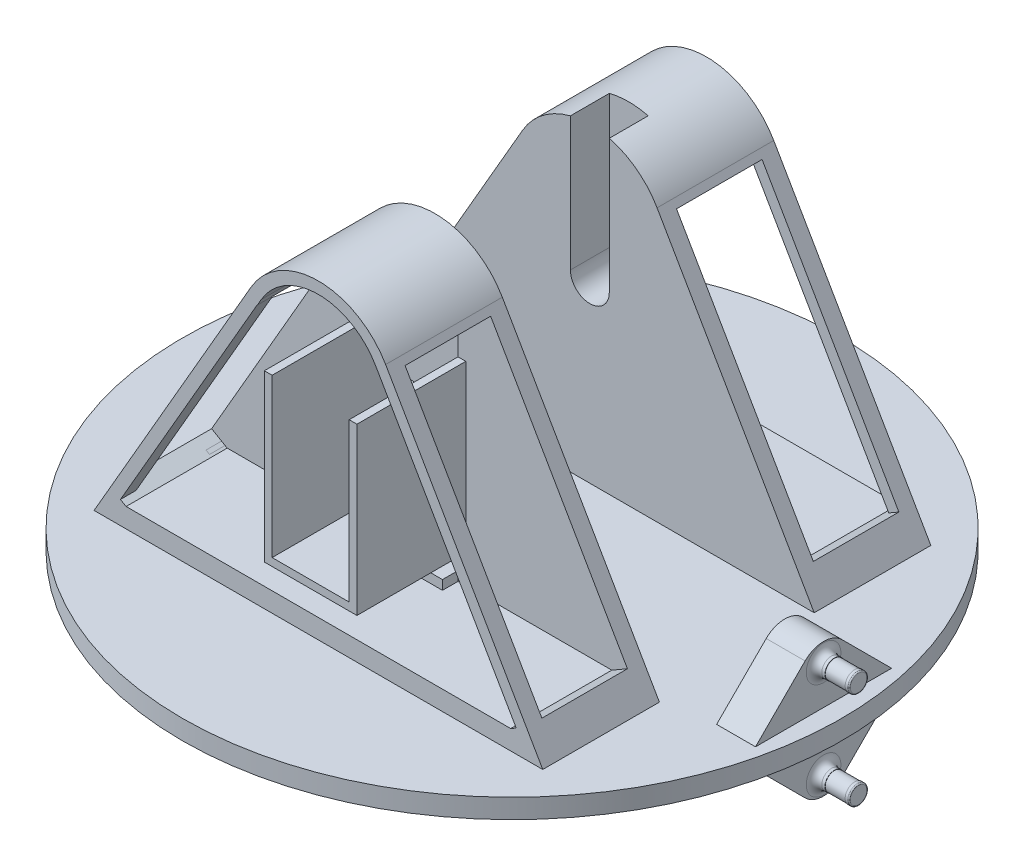
from build123d import *

# Parameters (mm, degrees)
SKETCH2_W            = 200
SKETCH2_H            = 200
BOSS_EXTRUDE2_DEPTH  = 60
BOSS_EXTRUDE3_START  = -38
BOSS_EXTRUDE3_DEPTH  = 41
SKETCH5_W            = 180
SKETCH5_H            = 180
CUT_EXTRUDE2_DEPTH   = 50
BOSS_EXTRUDE4_START  = -51.2
BOSS_EXTRUDE4_DEPTH  = 30
CUT_EXTRUDE3_DEPTH   = 35
SKETCH9_R            = 5
CUT_EXTRUDE4_DEPTH   = 10
CUT_EXTRUDE6_DEPTH   = 26
SKETCH11_W           = 120
SKETCH11_H           = 10
CUT_EXTRUDE7_DEPTH   = 26
SKETCH12_W           = 180
SKETCH12_H           = 50
CUT_EXTRUDE8_DEPTH   = 200
SKETCH13_W           = 180
SKETCH13_H           = 50
CUT_EXTRUDE9_DEPTH   = 200
SKETCH15_W           = 19.8
SKETCH15_H           = 40.6
SKETCH15_R           = 4.016151872
CUT_EXTRUDE11_DEPTH  = 10
BOSS_EXTRUDE5_DEPTH  = 26
SKETCH20_W           = 19.8
SKETCH20_H           = 7
CUT_EXTRUDE14_DEPTH  = 8.2
SKETCH22_W           = 22
SKETCH22_H           = 68.38628635
SKETCH22_W_2         = 33
SKETCH22_H_2         = 70.357034464
CUT_EXTRUDE16_DEPTH  = 6
CUT_EXTRUDE17_DEPTH  = 150
SKETCH24_W           = 190
SKETCH24_H           = 55
CUT_EXTRUDE18_DEPTH  = 200
SKETCH41_W           = 200
SKETCH41_H           = 200
SKETCH41_W_2         = 115.381197846
SKETCH41_H_2         = 110.8
CUT_EXTRUDE25_DEPTH  = 100
CUT_EXTRUDE26_DEPTH  = 26
SKETCH43_R           = 85
BOSS_EXTRUDE9_DEPTH  = 5
CUT_EXTRUDE27_DEPTH  = 11
BOSS_EXTRUDE10_DEPTH = 4
BOSS_EXTRUDE11_DEPTH = 24
BOSS_EXTRUDE12_DEPTH = 26
BOSS_EXTRUDE14_DEPTH = 4
CUT_EXTRUDE29_DEPTH  = 18
CUT_EXTRUDE30_DEPTH  = 2
CUT_EXTRUDE31_DEPTH  = 2
SKETCH55_W           = 19.8
SKETCH55_H           = 2.410200662
BOSS_EXTRUDE16_DEPTH = 4
SKETCH56_W           = 22
SKETCH56_H           = 70.356823689
CUT_EXTRUDE32_DEPTH  = 4
BOSS_EXTRUDE17_DEPTH = 26
BOSS_EXTRUDE18_DEPTH = 26
BOSS_EXTRUDE19_START = 170
BOSS_EXTRUDE19_DEPTH = 10
SKETCH60_R           = 2.45
BOSS_EXTRUDE20_DEPTH = 9
FILLET1_R            = 0.3
CUT_EXTRUDE33_START  = -1
SKETCH61_R           = 2.45
SKETCH61_R_2         = 2.375
CUT_EXTRUDE33_DEPTH  = 5.2
FILLET2_R            = 2
BOSS_EXTRUDE21_START = 140
BOSS_EXTRUDE21_DEPTH = 10
SKETCH63_R           = 2.45
BOSS_EXTRUDE22_DEPTH = 9
FILLET3_R            = 0.3
FILLET4_R            = 2
CUT_EXTRUDE34_START  = -1
SKETCH64_R           = 2.45
SKETCH64_R_2         = 2.375
CUT_EXTRUDE34_DEPTH  = 5.2
SKETCH67_R           = 95.168377016
SKETCH67_R_2         = 84.75
CUT_EXTRUDE36_DEPTH  = 5


with BuildPart() as part:
    # Sketch2 → Boss-Extrude2 (new body)
    with BuildSketch(Plane(origin=(0, 0, 0), x_dir=(1, 0, 0), z_dir=(0, 1, 0))):
        with Locations((100, 100)):
            Rectangle(SKETCH2_W, SKETCH2_H)
    extrude(amount=BOSS_EXTRUDE2_DEPTH)

    # Sketch3 → Boss-Extrude3 (add)
    with BuildSketch(Plane.XY.offset(BOSS_EXTRUDE3_START)):
        with BuildLine():
            Line((40, 60), (80.980762114, 130.980762114))
            ThreePointArc((80.980762114, 130.980762114), (100, 141.961524227), (119.019237886, 130.980762114))
            Line((119.019237886, 130.980762114), (160, 60))
            Line((160, 60), (40, 60))
        make_face()
    extrude(amount=-BOSS_EXTRUDE3_DEPTH)

    # Sketch5 → Cut-Extrude2 (cut)
    with BuildSketch(Plane.XZ):
        with Locations((100, -100)):
            Rectangle(SKETCH5_W, SKETCH5_H)
    extrude(amount=-CUT_EXTRUDE2_DEPTH, mode=Mode.SUBTRACT)

    # Sketch7 → Boss-Extrude4 (add)
    with BuildSketch(Plane(origin=(0, 0, -200), x_dir=(-1, 0, 0), z_dir=(0, 0, -1)).offset(BOSS_EXTRUDE4_START)):
        with BuildLine():
            Line((-160, 60), (-40, 60))
            Line((-40, 60), (-80.980762114, 130.980762114))
            ThreePointArc((-80.980762114, 130.980762114), (-100, 141.961524227), (-119.019237886, 130.980762114))
            Line((-119.019237886, 130.980762114), (-160, 60))
        make_face()
    extrude(amount=-BOSS_EXTRUDE4_DEPTH)

    # Sketch8 → Cut-Extrude3 (cut)
    with BuildSketch(Plane.XY.offset(-38)):
        with BuildLine():
            Line((48.660254038, 65), (151.339745962, 65))
            Line((151.339745962, 65), (114.689110868, 128.480762114))
            ThreePointArc((114.689110868, 128.480762114), (100, 136.961524227), (85.310889132, 128.480762114))
            Line((85.310889132, 128.480762114), (48.660254038, 65))
        make_face()
    extrude(amount=-CUT_EXTRUDE3_DEPTH, mode=Mode.SUBTRACT)

    # Sketch9 → Cut-Extrude4 (cut)
    with BuildSketch(Plane.XY.offset(-118.8)):
        with BuildLine():
            Line((95, 141.384773704), (95, 105))
            ThreePointArc((95, 105), (100, 110), (105, 105))
            Line((105, 105), (105, 141.384773704))
            ThreePointArc((105, 141.384773704), (100, 141.961524227), (95, 141.384773704))
        make_face()
        with Locations((100, 105)):
            Circle(SKETCH9_R)
    extrude(amount=-CUT_EXTRUDE4_DEPTH, mode=Mode.SUBTRACT)

    # Sketch10 → Cut-Extrude6 (cut)
    with BuildSketch(Plane(origin=(0, 0, -148.8), x_dir=(-1, 0, 0), z_dir=(0, 0, -1))):
        with BuildLine():
            Line((-110, 105), (-110, 133.700120587))
            ThreePointArc((-110, 133.700120587), (-112.617387787, 131.335555987), (-114.689110868, 128.480762114))
            Line((-114.689110868, 128.480762114), (-151.339745962, 65))
            Line((-151.339745962, 65), (-48.660254038, 65))
            Line((-48.660254038, 65), (-85.310889132, 128.480762114))
            ThreePointArc((-85.310889132, 128.480762114), (-87.382612213, 131.335555987), (-90, 133.700120587))
            Line((-90, 133.700120587), (-90, 105))
            ThreePointArc((-90, 105), (-100, 95), (-110, 105))
        make_face()
    extrude(amount=-CUT_EXTRUDE6_DEPTH, mode=Mode.SUBTRACT)

    # Sketch11 → Cut-Extrude7 (cut)
    with BuildSketch(Plane(origin=(0, 60, 0), x_dir=(1, 0, 0), z_dir=(0, 1, 0))):
        with Locations((100, 113.8)):
            Rectangle(SKETCH11_W, SKETCH11_H)
    extrude(amount=-CUT_EXTRUDE7_DEPTH, mode=Mode.SUBTRACT)

    # Sketch12 → Cut-Extrude8 (cut)
    with BuildSketch(Plane(origin=(200, 0, 0), x_dir=(0, 0, -1), z_dir=(1, 0, 0))):
        with Locations((100, 25)):
            Rectangle(SKETCH12_W, SKETCH12_H)
    extrude(amount=-CUT_EXTRUDE8_DEPTH, mode=Mode.SUBTRACT)

    # Sketch13 → Cut-Extrude9 (cut)
    with BuildSketch(Plane.XY):
        with Locations((100, 25)):
            Rectangle(SKETCH13_W, SKETCH13_H)
    extrude(amount=-CUT_EXTRUDE9_DEPTH, mode=Mode.SUBTRACT)

    # Sketch15 → Cut-Extrude11 (cut)
    with BuildSketch(Plane.XY.offset(-73)):
        with Locations((100, 94.7)):
            Rectangle(SKETCH15_W, SKETCH15_H)
        with Locations((100, 105)):
            Circle(SKETCH15_R, mode=Mode.SUBTRACT)
        with Locations((100, 105)):
            Circle(SKETCH15_R)
    extrude(amount=-CUT_EXTRUDE11_DEPTH, mode=Mode.SUBTRACT)

    # Sketch16 → Boss-Extrude5 (add)
    with BuildSketch(Plane.XY.offset(-73)):
        Polygon((88.1, 115), (88.1, 72.4), (111.9, 72.4), (111.9, 115), (109.9, 115), (109.9, 74.4), (90.1, 74.4), (90.1, 115), align=None)
    extrude(amount=BOSS_EXTRUDE5_DEPTH)

    # Sketch20 → Cut-Extrude14 (cut)
    with BuildSketch(Plane(origin=(0, 0, -79), x_dir=(-1, 0, 0), z_dir=(0, 0, -1))):
        with Locations((-100, 118.5)):
            Rectangle(SKETCH20_W, SKETCH20_H)
        with Locations((-100, 70.9)):
            Rectangle(SKETCH20_W, SKETCH20_H)
    extrude(amount=-CUT_EXTRUDE14_DEPTH, mode=Mode.SUBTRACT)

    # Sketch22 → Cut-Extrude16 (cut)
    with BuildSketch(Plane(origin=(4.019237886, -2.320508076, 0), x_dir=(0, 0, 1), z_dir=(-0.8660254037844397, 0.49999999999999806, 0))):
        with Locations((-133.8, 115.729905279)):
            Rectangle(SKETCH22_W, SKETCH22_H)
        with Locations((-58.5, 116.744531222)):
            Rectangle(SKETCH22_W_2, SKETCH22_H_2)
    extrude(amount=-CUT_EXTRUDE16_DEPTH, mode=Mode.SUBTRACT)

    # Sketch23 → Cut-Extrude17 (cut)
    with BuildSketch(Plane.XY.offset(-38)):
        with BuildLine():
            Line((43.464101615, 62), (42.309401077, 60))
            Line((42.309401077, 60), (36.951802896, 60))
            Line((36.951802896, 60), (100, 183.688158135))
            Line((100, 183.688158135), (162.604774917, 60))
            Line((162.604774917, 60), (157.690598923, 60))
            Line((157.690598923, 60), (156.535898385, 62))
            Line((156.535898385, 62), (117.287187079, 129.980762114))
            ThreePointArc((117.287187079, 129.980762114), (100, 139.961524227), (82.712812921, 129.980762114))
            Line((82.712812921, 129.980762114), (43.464101615, 62))
        make_face()
    extrude(amount=-CUT_EXTRUDE17_DEPTH, mode=Mode.SUBTRACT)

    # Sketch24 → Cut-Extrude18 (cut)
    with BuildSketch(Plane(origin=(0, 0, -200), x_dir=(-1, 0, 0), z_dir=(0, 0, -1))):
        with Locations((-100, 27.5)):
            Rectangle(SKETCH24_W, SKETCH24_H)
    extrude(amount=-CUT_EXTRUDE18_DEPTH, mode=Mode.SUBTRACT)

    # Sketch41 → Cut-Extrude25 (cut)
    with BuildSketch(Plane(origin=(0, 60, 0), x_dir=(1, 0, 0), z_dir=(0, 1, 0))):
        with Locations((100, 100)):
            Rectangle(SKETCH41_W, SKETCH41_H)
        with Locations((100, 93.4)):
            Rectangle(SKETCH41_W_2, SKETCH41_H_2, mode=Mode.SUBTRACT)
    extrude(amount=-CUT_EXTRUDE25_DEPTH, mode=Mode.SUBTRACT)


with BuildPart() as cut_extrude25_piece_1:
    # of the separate pieces the step leaves, piece 1, a body of its own (cut_extrude25_pieces)
    add(part.part.solids().sort_by_distance((42.309401077, 55, -108.8))[0])



with BuildPart() as cut_extrude25_piece_2:
    # of the separate pieces the step leaves, piece 2, a body of its own (cut_extrude25_pieces)
    add(part.part.solids().sort_by_distance((42.309401077, 55, -118.8))[0])

    # Sketch38 → Cut-Extrude26 (cut)
    with BuildSketch(Plane(origin=(0, 0, -148.8), x_dir=(-1, 0, 0), z_dir=(0, 0, -1))):
        with BuildLine():
            Line((-110, 133.700120587), (-107, 135.763853262))
            Line((-107, 135.763853262), (-107, 105))
            ThreePointArc((-107, 105), (-100, 98), (-93, 105))
            Line((-93, 105), (-93, 135.763853262))
            Line((-93, 135.763853262), (-90, 133.700120587))
            Line((-90, 133.700120587), (-90, 105))
            ThreePointArc((-90, 105), (-100, 95), (-110, 105))
            Line((-110, 105), (-110, 133.700120587))
        make_face()
    extrude(amount=-CUT_EXTRUDE26_DEPTH, mode=Mode.SUBTRACT)


with BuildPart() as cut_extrude25_piece_1_1:
    add(cut_extrude25_piece_1.part)

    add(cut_extrude25_piece_2.part)  # Boss-Extrude9 merges Cut-Extrude25 piece 2
    # Sketch43 → Boss-Extrude9 (add)
    with BuildSketch(Plane.XZ.offset(-55)):
        with Locations(Location((100, -98.8, 0), (0, 0, 270))):
            Circle(SKETCH43_R)
    extrude(amount=-BOSS_EXTRUDE9_DEPTH)

    # Sketch45 → Cut-Extrude27 (cut)
    with BuildSketch(Plane.XY.offset(-38)):
        with BuildLine():
            Line((42.309401077, 60), (82.712812921, 129.980762114))
            ThreePointArc((82.712812921, 129.980762114), (100, 139.961524227), (117.287187079, 129.980762114))
            Line((117.287187079, 129.980762114), (157.690598923, 60))
            Line((157.690598923, 60), (42.309401077, 60))
        make_face()
        with BuildLine():
            Line((151.339745962, 65), (114.689110868, 128.480762114))
            ThreePointArc((114.689110868, 128.480762114), (100, 136.961524227), (85.310889132, 128.480762114))
            Line((85.310889132, 128.480762114), (48.660254038, 65))
            Line((48.660254038, 65), (151.339745962, 65))
        make_face(mode=Mode.SUBTRACT)
    extrude(amount=-CUT_EXTRUDE27_DEPTH, mode=Mode.SUBTRACT)

    # Sketch46 → Boss-Extrude10 (add)
    with BuildSketch(Plane.XY.offset(-49)):
        Polygon((81.712812921, 128.248711306), (46.534295689, 67.317732125), (49.094273419, 65.839728294), (84.272790651, 126.770707475), align=None)
    extrude(amount=-BOSS_EXTRUDE10_DEPTH)

    # Sketch47 → Boss-Extrude11 (add)
    with BuildSketch(Plane.XY.offset(-73)):
        Polygon((49.1323719, 65.817732125), (50.548725488, 65), (48.660254038, 65), align=None)
    extrude(amount=BOSS_EXTRUDE11_DEPTH)

    # Sketch48 → Boss-Extrude12 (add)
    with BuildSketch(Plane(origin=(0, 0, -122.8), x_dir=(-1, 0, 0), z_dir=(0, 0, -1))):
        Polygon((-49.117745958, 65.792399249), (-50.490221717, 65), (-48.660254038, 65), align=None)
    extrude(amount=BOSS_EXTRUDE12_DEPTH)

    # Sketch49 → Boss-Extrude14 (add)
    with BuildSketch(Plane.XY.offset(-75)):
        Polygon((49.998397304, 65.317732125), (49.094273419, 65.839728294), (84.272790651, 126.770707475), (85.176914536, 126.248711306), align=None)
    extrude(amount=BOSS_EXTRUDE14_DEPTH)

    # Sketch52 → Cut-Extrude29 (cut)
    with BuildSketch(Plane(origin=(0, 0, -148.8), x_dir=(-1, 0, 0), z_dir=(0, 0, -1))):
        with BuildLine():
            Line((-93, 135.763853262), (-93, 105))
            ThreePointArc((-93, 105), (-100, 98), (-107, 105))
            Line((-107, 105), (-107, 135.763853262))
            ThreePointArc((-107, 135.763853262), (-100, 137.248161341), (-93, 135.763853262))
        make_face()
    extrude(amount=-CUT_EXTRUDE29_DEPTH, mode=Mode.SUBTRACT)

    # Sketch53 → Cut-Extrude30 (cut)
    with BuildSketch(Plane.XY.offset(-71)):
        Polygon((85.176914536, 126.248711306), (84.272790651, 126.770707475), (49.090707581, 65.833552081), (49.994831466, 65.311555913), align=None)
    extrude(amount=-CUT_EXTRUDE30_DEPTH, mode=Mode.SUBTRACT)

    # Sketch54 → Cut-Extrude31 (cut)
    with BuildSketch(Plane.XY.offset(-73)):
        with BuildLine():
            Line((49.090707581, 65.833552081), (49.994831466, 65.311555913))
            Line((49.994831466, 65.311555913), (49.998397304, 65.317732125))
            Line((49.998397304, 65.317732125), (50.548725488, 65))
            Line((50.548725488, 65), (151.339745962, 65))
            Line((151.339745962, 65), (114.689110868, 128.480762114))
            ThreePointArc((114.689110868, 128.480762114), (100, 136.961524227), (85.310889132, 128.480762114))
            Line((85.310889132, 128.480762114), (84.310889132, 126.748711306))
            Line((84.310889132, 126.748711306), (84.272790651, 126.770707475))
            Line((84.272790651, 126.770707475), (49.094273419, 65.839728294))
            Line((49.094273419, 65.839728294), (49.090707581, 65.833552081))
        make_face()
        Polygon((90.1, 122), (109.9, 122), (109.9, 115), (111.9, 115), (111.9, 72.4), (109.9, 72.4), (109.9, 67.4), (90.1, 67.4), (90.1, 72.4), (88.1, 72.4), (88.1, 115), (90.1, 115), align=None, mode=Mode.SUBTRACT)
    extrude(amount=-CUT_EXTRUDE31_DEPTH, mode=Mode.SUBTRACT)

    # Sketch55 → Boss-Extrude16 (add)
    with BuildSketch(Plane.XY.offset(-75)):
        with Locations((100, 66.194899669)):
            Rectangle(SKETCH55_W, SKETCH55_H)
    extrude(amount=BOSS_EXTRUDE16_DEPTH)

    # Sketch56 → Cut-Extrude32 (cut)
    with BuildSketch(Plane(origin=(144.248711306, 83.282032303, 0), x_dir=(0, 0, -1), z_dir=(0.8660254037844362, 0.5000000000000044, 0))):
        with Locations((64, 16.744636609)):
            Rectangle(SKETCH56_W, SKETCH56_H)
        with Locations((133.8, 16.744636609)):
            Rectangle(SKETCH56_W, SKETCH56_H)
    extrude(amount=-CUT_EXTRUDE32_DEPTH, mode=Mode.SUBTRACT)

    # Sketch57 → Boss-Extrude17 (add)
    with BuildSketch(Plane.XY.offset(-75)):
        Polygon((150.867522712, 65.817914662), (149.450852961, 65), (151.339745962, 65), align=None)
    extrude(amount=BOSS_EXTRUDE17_DEPTH)

    # Sketch58 → Boss-Extrude18 (add)
    with BuildSketch(Plane(origin=(0, 0, -122.8), x_dir=(-1, 0, 0), z_dir=(0, 0, -1))):
        Polygon((-150.867522712, 65.817914662), (-151.339745962, 65), (-149.450852961, 65), align=None)
    extrude(amount=BOSS_EXTRUDE18_DEPTH)

    # Sketch59 → Boss-Extrude19 (add)
    with BuildSketch(Plane(origin=(0, 0, 0), x_dir=(0, 0, -1), z_dir=(1, 0, 0)).offset(BOSS_EXTRUDE19_START)):
        with BuildLine():
            Line((81.4, 60), (94.15, 72.75))
            ThreePointArc((94.15, 72.75), (98.9, 74.717514421), (103.65, 72.75))
            Line((103.65, 72.75), (116.4, 60))
            Line((116.4, 60), (81.4, 60))
        make_face()
        with BuildLine():
            Line((81.4, 55), (116.4, 55))
            Line((116.4, 55), (103.65, 42.25))
            ThreePointArc((103.65, 42.25), (98.9, 40.282485579), (94.15, 42.25))
            Line((94.15, 42.25), (81.4, 55))
        make_face()
    extrude(amount=BOSS_EXTRUDE19_DEPTH)

    # Sketch60 → Boss-Extrude20 (add)
    with BuildSketch(Plane(origin=(180, 0, 0), x_dir=(0, 0, -1), z_dir=(1, 0, 0))):
        with Locations(Location((98.9, 70, 0), (0, 0, 180))):
            Circle(SKETCH60_R)
        with Locations(Location((98.9, 45, 0), (0, 0, 180))):
            Circle(SKETCH60_R)
    extrude(amount=BOSS_EXTRUDE20_DEPTH)

    # Fillet1
    fillet1_edges = [cut_extrude25_piece_1_1.edges().sort_by_distance(p)[0] for p in [
        (189, 70, -101.35),
        (189, 45, -101.35),
    ]]
    fillet(fillet1_edges, radius=FILLET1_R)

    # Sketch61 → Cut-Extrude33 (cut)
    with BuildSketch(Plane(origin=(189, 0, 0), x_dir=(0, 0, -1), z_dir=(1, 0, 0)).offset(CUT_EXTRUDE33_START)):
        with Locations(Location((98.9, 70, 0), (0, 0, 180))):
            Circle(SKETCH61_R)
        with Locations((98.9, 70)):
            Circle(SKETCH61_R_2, mode=Mode.SUBTRACT)
        with Locations(Location((98.9, 45, 0), (0, 0, 180))):
            Circle(SKETCH61_R)
        with Locations(Location((98.9, 45, 0), (0, 0, 180))):
            Circle(SKETCH61_R_2, mode=Mode.SUBTRACT)
    extrude(amount=-CUT_EXTRUDE33_DEPTH, mode=Mode.SUBTRACT)

    # Fillet2
    fillet2_edges = [cut_extrude25_piece_1_1.edges().sort_by_distance(p)[0] for p in [
        (180, 70, -101.35),
        (180, 45, -101.35),
    ]]
    fillet(fillet2_edges, radius=FILLET2_R)

    # Sketch62 → Boss-Extrude21 (add)
    with BuildSketch(Plane.ZY.offset(-170).offset(BOSS_EXTRUDE21_START)):
        with BuildLine():
            Line((-81.4, 55), (-94.15, 42.25))
            ThreePointArc((-94.15, 42.25), (-98.9, 40.282485579), (-103.65, 42.25))
            Line((-103.65, 42.25), (-116.4, 55))
            Line((-116.4, 55), (-81.4, 55))
        make_face()
    extrude(amount=BOSS_EXTRUDE21_DEPTH)

    # Sketch63 → Boss-Extrude22 (add)
    with BuildSketch(Plane.ZY.offset(-20)):
        with Locations((-98.9, 45)):
            Circle(SKETCH63_R)
    extrude(amount=BOSS_EXTRUDE22_DEPTH)

    # Fillet3
    fillet3_edges = [cut_extrude25_piece_1_1.edges().sort_by_distance(p)[0] for p in [
        (11, 45, -101.35),
    ]]
    fillet(fillet3_edges, radius=FILLET3_R)

    # Fillet4
    fillet4_edges = [cut_extrude25_piece_1_1.edges().sort_by_distance(p)[0] for p in [
        (20, 45, -101.35),
    ]]
    fillet(fillet4_edges, radius=FILLET4_R)

    # Sketch64 → Cut-Extrude34 (cut)
    with BuildSketch(Plane.ZY.offset(-11).offset(CUT_EXTRUDE34_START)):
        with Locations((-98.9, 45)):
            Circle(SKETCH64_R)
        with Locations((-98.9, 45)):
            Circle(SKETCH64_R_2, mode=Mode.SUBTRACT)
    extrude(amount=-CUT_EXTRUDE34_DEPTH, mode=Mode.SUBTRACT)

    # Sketch67 → Cut-Extrude36 (cut)
    with BuildSketch(Plane(origin=(0, 60, 0), x_dir=(1, 0, 0), z_dir=(0, 1, 0))):
        with Locations((100, 98.8)):
            Circle(SKETCH67_R)
        with Locations(Location((100, 98.8, 0), (0, 0, 270))):
            Circle(SKETCH67_R_2, mode=Mode.SUBTRACT)
    extrude(amount=-CUT_EXTRUDE36_DEPTH, mode=Mode.SUBTRACT)


solid = cut_extrude25_piece_1_1.part
